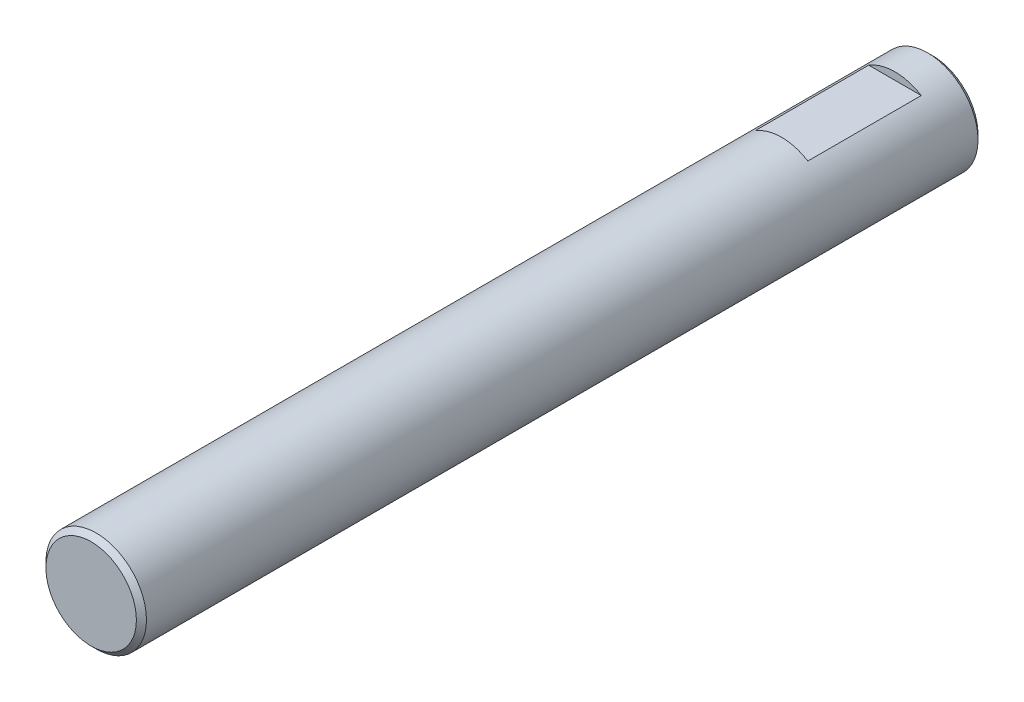
from build123d import *

# Parameters (mm, degrees)
SKETCH1_R               = 1.995
BOSS_EXTRUDE1_DEPTH     = 33.4
SKETCH2_W               = 4.5
SKETCH2_H               = 0.920377874
CUT_EXTRUDE1_DEPTH      = 2.995
CUT_EXTRUDE1_DEPTH_BACK = 2.995
CHAMFER1_SIZE           = 0.2


with BuildPart() as part:
    # Sketch1 → Boss-Extrude1 (new body)
    with BuildSketch(Plane.XY):
        Circle(SKETCH1_R)
    extrude(amount=BOSS_EXTRUDE1_DEPTH)

    # Sketch2 → Cut-Extrude1 (cut, two sides)
    with BuildSketch(Plane(origin=(0, 0, 0), x_dir=(0, 0, -1), z_dir=(1, 0, 0))) as cut_extrude1_sk:
        with Locations((-3.75, 2.160188937)):
            Rectangle(SKETCH2_W, SKETCH2_H)
        with Locations((-3.75, -2.160188937)):
            Rectangle(SKETCH2_W, SKETCH2_H)
    extrude(amount=CUT_EXTRUDE1_DEPTH, mode=Mode.SUBTRACT)
    extrude(cut_extrude1_sk.sketch, amount=-CUT_EXTRUDE1_DEPTH_BACK, mode=Mode.SUBTRACT)

    # Chamfer1
    chamfer1_edges = [part.edges().sort_by_distance(p)[0] for p in [
        (-1.995, 0, 0),
        (-1.995, 0, 33.4),
    ]]
    chamfer(chamfer1_edges, length=CHAMFER1_SIZE)


solid = part.part
